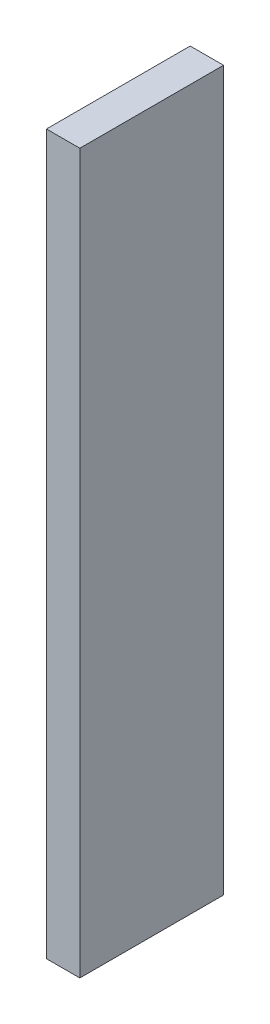
from build123d import *

# Parameters (mm, degrees)
SKETCH1_W           = 5.8
SKETCH1_H           = 125
BOSS_EXTRUDE1_DEPTH = 25


with BuildPart() as part:
    # Sketch1 → Boss-Extrude1 (new body)
    with BuildSketch(Plane.XY):
        with Locations((-36.1, 0)):
            Rectangle(SKETCH1_W, SKETCH1_H)
    extrude(amount=BOSS_EXTRUDE1_DEPTH)


solid = part.part
